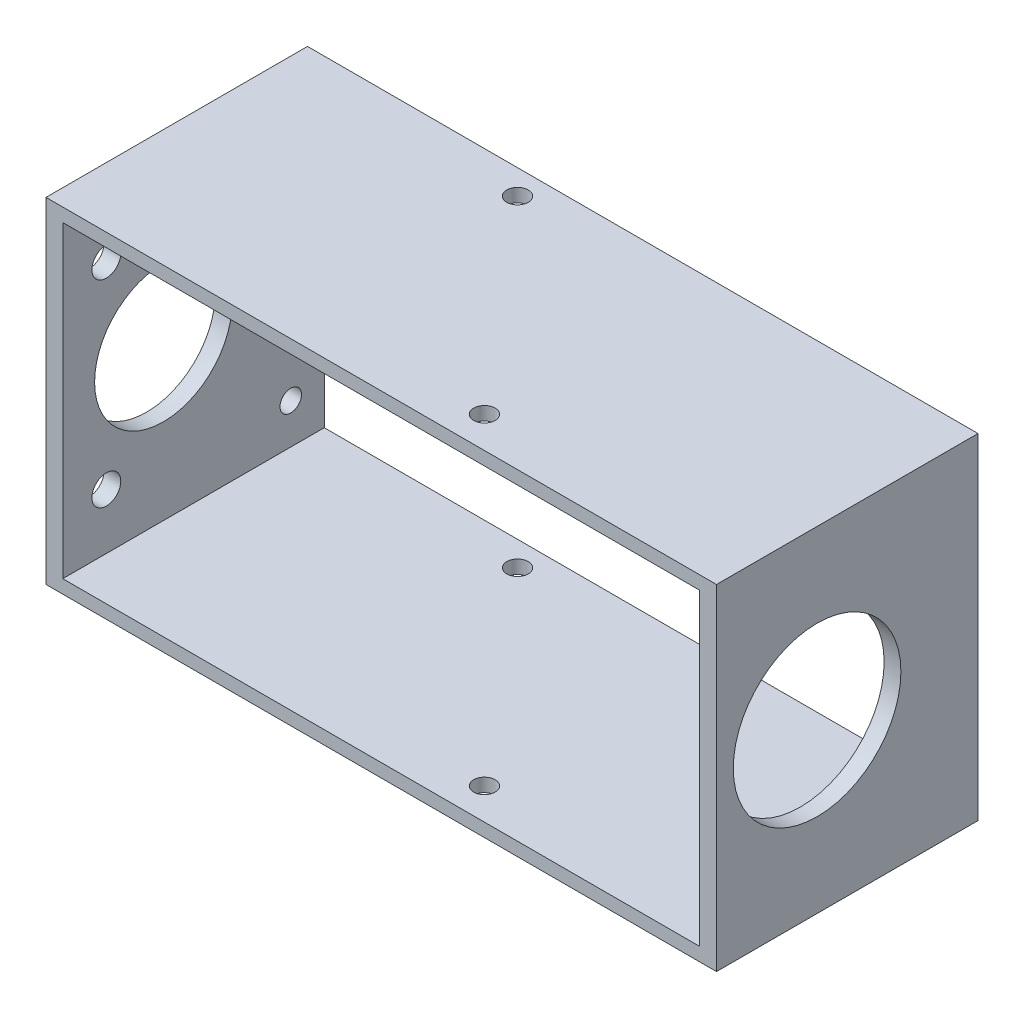
from build123d import *

# Parameters (mm, degrees)
SKETCH_1_W          = 100
SKETCH_1_H          = 50
SKETCH_1_W_2        = 95
SKETCH_1_H_2        = 46
EXTRUDE_1_DEPTH     = 19.5
SKETCH_2_R          = 1.6
CUT_EXTRUDE_1_DEPTH = 51
CUT_EXTRUDE_2_REACH = 102
SKETCH_3_R          = 10.25
SKETCH_3_R_2        = 2.15
SKETCH_3_R_3        = 1.6
CUT_EXTRUDE_3_REACH = 102
SKETCH_4_R          = 12.5


with BuildPart() as part:
    # ｽｹｯﾁ1 → ﾎﾞｽ - 押し出し1 (new body, symmetric)
    with BuildSketch(Plane.XY):
        Rectangle(SKETCH_1_W, SKETCH_1_H)
        Rectangle(SKETCH_1_W_2, SKETCH_1_H_2, mode=Mode.SUBTRACT)
    extrude(amount=EXTRUDE_1_DEPTH, both=True)

    # ｽｹｯﾁ2 → ｶｯﾄ - 押し出し1 (cut, through all)
    with BuildSketch(Plane(origin=(0, 25, 0), x_dir=(1, 0, 0), z_dir=(0, 1, 0))):
        with Locations((-15, 15.820888862)):
            Circle(SKETCH_2_R)
        with Locations((10.711504387, -14.820888862)):
            Circle(SKETCH_2_R)
    extrude(amount=-CUT_EXTRUDE_1_DEPTH, mode=Mode.SUBTRACT)

    # ｽｹｯﾁ3 → ｶｯﾄ - 押し出し2 (cut, up to next)
    with BuildSketch(Plane.ZY.offset(50), mode=Mode.PRIVATE) as cut_extrude_2_sk1:
        with Locations((4.5, 0)):
            Circle(SKETCH_3_R)
    cut_extrude_2_tool1 = extrude(cut_extrude_2_sk1.sketch, amount=-CUT_EXTRUDE_2_REACH, mode=Mode.PRIVATE) & part.part
    add(cut_extrude_2_tool1.solids().sort_by_distance((-50, 0, 4.5))[0], mode=Mode.SUBTRACT)
    # ｽｹｯﾁ3 → ｶｯﾄ - 押し出し2 (cut, up to next)
    with BuildSketch(Plane.ZY.offset(50), mode=Mode.PRIVATE) as cut_extrude_2_sk2:
        with Locations((-12.5, 0)):
            Circle(SKETCH_3_R_2)
    cut_extrude_2_tool2 = extrude(cut_extrude_2_sk2.sketch, amount=-CUT_EXTRUDE_2_REACH, mode=Mode.PRIVATE) & part.part
    add(cut_extrude_2_tool2.solids().sort_by_distance((-50, 0, -12.5))[0], mode=Mode.SUBTRACT)
    # ｽｹｯﾁ3 → ｶｯﾄ - 押し出し2 (cut, up to next)
    with BuildSketch(Plane.ZY.offset(50), mode=Mode.PRIVATE) as cut_extrude_2_sk3:
        with Locations((13, 14.722431864)):
            Circle(SKETCH_3_R_2)
    cut_extrude_2_tool3 = extrude(cut_extrude_2_sk3.sketch, amount=-CUT_EXTRUDE_2_REACH, mode=Mode.PRIVATE) & part.part
    add(cut_extrude_2_tool3.solids().sort_by_distance((-50, 14.722432, 13))[0], mode=Mode.SUBTRACT)
    # ｽｹｯﾁ3 → ｶｯﾄ - 押し出し2 (cut, up to next)
    with BuildSketch(Plane.ZY.offset(50), mode=Mode.PRIVATE) as cut_extrude_2_sk4:
        with Locations((13, -14.722431864)):
            Circle(SKETCH_3_R_2)
    cut_extrude_2_tool4 = extrude(cut_extrude_2_sk4.sketch, amount=-CUT_EXTRUDE_2_REACH, mode=Mode.PRIVATE) & part.part
    add(cut_extrude_2_tool4.solids().sort_by_distance((-50, -14.722432, 13))[0], mode=Mode.SUBTRACT)
    # ｽｹｯﾁ3 → ｶｯﾄ - 押し出し2 (cut, up to next)
    with BuildSketch(Plane.ZY.offset(50), mode=Mode.PRIVATE) as cut_extrude_2_sk5:
        with Locations((-14.5, -17)):
            Circle(SKETCH_3_R_3)
    cut_extrude_2_tool5 = extrude(cut_extrude_2_sk5.sketch, amount=-CUT_EXTRUDE_2_REACH, mode=Mode.PRIVATE) & part.part
    add(cut_extrude_2_tool5.solids().sort_by_distance((-50, -17, -14.5))[0], mode=Mode.SUBTRACT)
    # ｽｹｯﾁ3 → ｶｯﾄ - 押し出し2 (cut, up to next)
    with BuildSketch(Plane.ZY.offset(50), mode=Mode.PRIVATE) as cut_extrude_2_sk6:
        with Locations((-14.5, 17)):
            Circle(SKETCH_3_R_3)
    cut_extrude_2_tool6 = extrude(cut_extrude_2_sk6.sketch, amount=-CUT_EXTRUDE_2_REACH, mode=Mode.PRIVATE) & part.part
    add(cut_extrude_2_tool6.solids().sort_by_distance((-50, 17, -14.5))[0], mode=Mode.SUBTRACT)

    # ｽｹｯﾁ4 → ｶｯﾄ - 押し出し3 (cut, up to next)
    with BuildSketch(Plane(origin=(50, 0, 0), x_dir=(0, 0, -1), z_dir=(1, 0, 0)), mode=Mode.PRIVATE) as cut_extrude_3_sk1:
        with Locations((-4.5, 0)):
            Circle(SKETCH_4_R)
    cut_extrude_3_tool1 = extrude(cut_extrude_3_sk1.sketch, amount=-CUT_EXTRUDE_3_REACH, mode=Mode.PRIVATE) & part.part
    add(cut_extrude_3_tool1.solids().sort_by_distance((50, 0, 4.5))[0], mode=Mode.SUBTRACT)


solid = part.part
